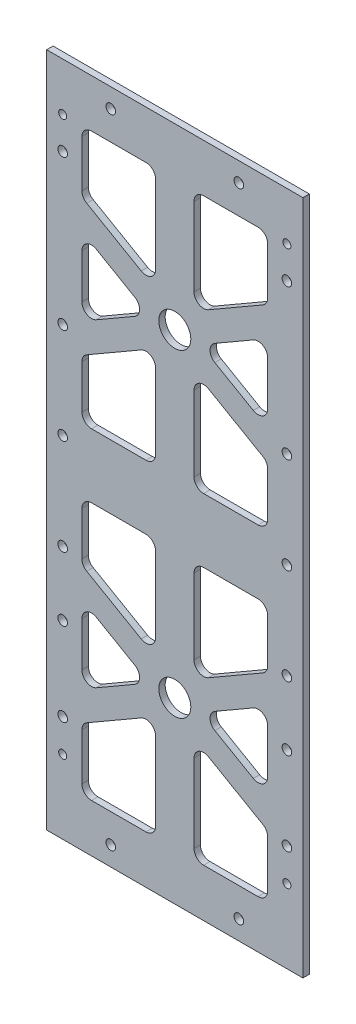
from build123d import *

# Parameters (mm, degrees)
SKETCH1_W                   = 88
SKETCH1_H                   = 211
BOSS_EXTRUDE1_DEPTH         = 2
CUT_EXTRUDE2_DEPTH          = 2
SKETCH4_R                   = 5
CUT_EXTRUDE3_DEPTH          = 3
FILLET2_R                   = 3
SKETCH23_W                  = 2
SKETCH23_H                  = 211
SKETCH23_W_2                = 2.150374681
CUT_EXTRUDE5_DEPTH          = 10
SKETCH29_W                  = 5.911493913
SKETCH29_H                  = 211
SKETCH29_W_2                = 4.036537762
CUT_EXTRUDE10_DEPTH         = 2
F_3_0MM_DOWEL_HOLE1_D       = 3
TAP_DRILL_FOR_M3X0_5_TAP1_D = 2.5


with BuildPart() as part:
    # Sketch1 → Boss-Extrude1 (new body)
    with BuildSketch(Plane.XY):
        with Locations((44, 105.5)):
            Rectangle(SKETCH1_W, SKETCH1_H)
    extrude(amount=BOSS_EXTRUDE1_DEPTH)

    # Sketch3 → Cut-Extrude2 (cut)
    with BuildSketch(Plane.XY.offset(2)):
        Polygon((73, 133.88804004), (50, 147.167096231), (50, 115.5), (73, 115.5), align=None)
        Polygon((38, 115.5), (38, 147.167096231), (15, 133.88804004), (15, 115.5), align=None)
        Polygon((15, 143.125644347), (36, 155.25), (15, 167.374355653), align=None)
        Polygon((73, 143.125644347), (73, 167.374355653), (52, 155.25), align=None)
        Polygon((73, 196), (50, 196), (50, 163.332903769), (73, 176.61195996), align=None)
        Polygon((38, 163.332903769), (38, 196), (15, 196), (15, 176.61195996), align=None)
    cut_extrude2 = extrude(amount=-CUT_EXTRUDE2_DEPTH, mode=Mode.SUBTRACT)

    # Sketch4 → Cut-Extrude3 (cut, through all)
    with BuildSketch(Plane.XY.offset(2)):
        with Locations((44, 155.25)):
            Circle(SKETCH4_R)
    cut_extrude3 = extrude(amount=-CUT_EXTRUDE3_DEPTH, mode=Mode.SUBTRACT)

    # Mirror2: Cut-Extrude2, Cut-Extrude3 across plane
    add(cut_extrude2.mirror(Plane.ZX.offset(105.5)), mode=Mode.SUBTRACT)
    add(cut_extrude3.mirror(Plane.ZX.offset(105.5)), mode=Mode.SUBTRACT)

    # Fillet2
    fillet2_edges = [part.edges().sort_by_distance(p)[0] for p in [
        (36, 55.75, 1),
        (15, 43.625644347, 1),
        (15, 67.874355653, 1),
        (38, 95.5, 1),
        (38, 63.832903769, 1),
        (15, 77.11195996, 1),
        (15, 95.5, 1),
        (73, 15, 1),
        (50, 15, 1),
        (50, 47.667096231, 1),
        (73, 34.38804004, 1),
        (73, 43.625644347, 1),
        (52, 55.75, 1),
        (73, 67.874355653, 1),
        (15, 15, 1),
        (15, 34.38804004, 1),
        (38, 47.667096231, 1),
        (38, 15, 1),
        (73, 77.11195996, 1),
        (50, 63.832903769, 1),
        (50, 95.5, 1),
        (73, 95.5, 1),
        (15, 167.374355653, 1),
        (36, 155.25, 1),
        (15, 143.125644347, 1),
        (38, 147.167096231, 1),
        (38, 115.5, 1),
        (15, 115.5, 1),
        (15, 133.88804004, 1),
        (50, 196, 1),
        (73, 196, 1),
        (73, 176.61195996, 1),
        (50, 163.332903769, 1),
        (52, 155.25, 1),
        (73, 167.374355653, 1),
        (73, 143.125644347, 1),
        (15, 176.61195996, 1),
        (15, 196, 1),
        (38, 196, 1),
        (38, 163.332903769, 1),
        (50, 147.167096231, 1),
        (73, 133.88804004, 1),
        (73, 115.5, 1),
        (50, 115.5, 1),
    ]]
    fillet(fillet2_edges, radius=FILLET2_R)

    # Sketch23 → Cut-Extrude5 (cut)
    with BuildSketch(Plane.XY.offset(2)):
        with Locations((87, 105.5)):
            Rectangle(SKETCH23_W, SKETCH23_H)
        with Locations((1.075187341, 105.5)):
            Rectangle(SKETCH23_W_2, SKETCH23_H)
    extrude(amount=-CUT_EXTRUDE5_DEPTH, mode=Mode.SUBTRACT)

    # Sketch29 → Cut-Extrude10 (cut)
    with BuildSketch(Plane(origin=(0, 0, 0), x_dir=(-1, 0, 0), z_dir=(0, 0, -1))):
        with Locations((-1.044253043, 105.5)):
            Rectangle(SKETCH29_W, SKETCH29_H)
        with Locations((-86.018268881, 105.5)):
            Rectangle(SKETCH29_W_2, SKETCH29_H)
    extrude(amount=-CUT_EXTRUDE10_DEPTH, mode=Mode.SUBTRACT)

    # Ø3.0mm Dowel Hole1 (through all)
    with Locations(Plane.XY.offset(2)):
        with Locations((24, 205), (64, 205), (9, 186), (79, 186), (9, 139.2), (79, 139.2), (79, 109.2), (9, 109.2), (9, 79.2), (79, 79.2), (79, 59.2), (9, 59.2), (9, 33.2), (79, 33.2), (64, 6), (24, 6)):
            Hole(F_3_0MM_DOWEL_HOLE1_D / 2)

    # Tap Drill for M3x0.5 Tap1 (through all)
    with Locations(Plane.XY.offset(2)):
        with Locations((9, 23), (79, 23), (9, 196), (79, 196)):
            Hole(TAP_DRILL_FOR_M3X0_5_TAP1_D / 2)


solid = part.part
